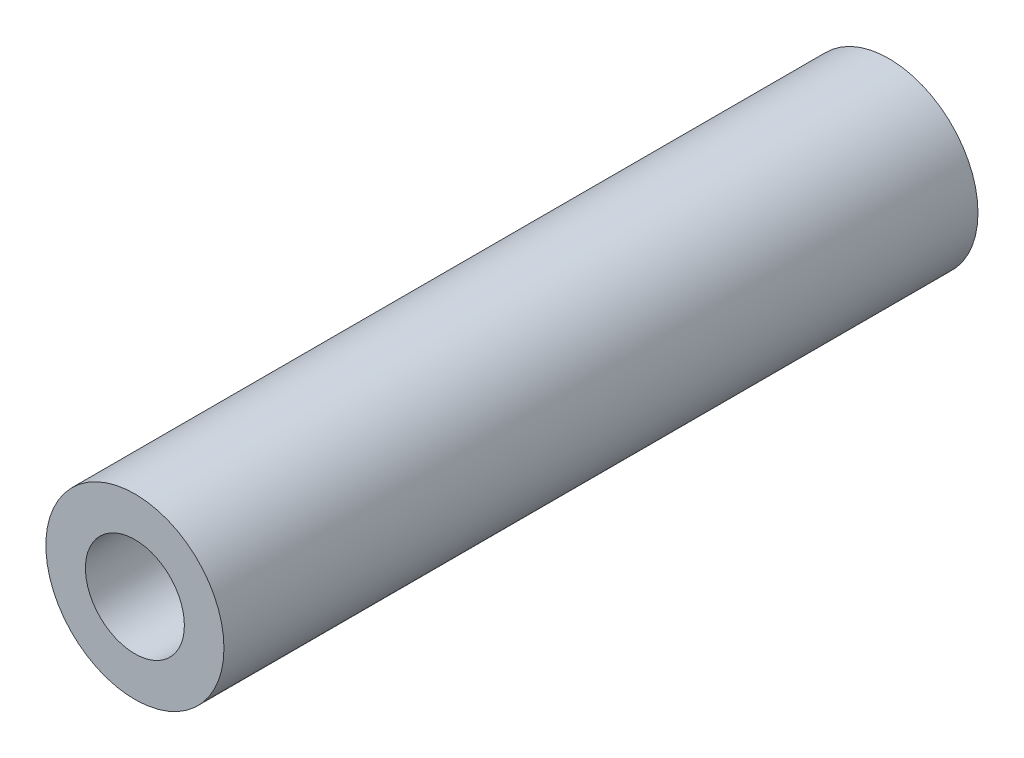
from build123d import *

# Parameters (mm, degrees)
SKETCH1_R           = 0.9
SKETCH1_R_2         = 0.5
BOSS_EXTRUDE1_DEPTH = 7.62


with BuildPart() as part:
    # Sketch1 → Boss-Extrude1 (new body)
    with BuildSketch(Plane.XY):
        Circle(SKETCH1_R)
        Circle(SKETCH1_R_2, mode=Mode.SUBTRACT)
    extrude(amount=BOSS_EXTRUDE1_DEPTH)


solid = part.part
